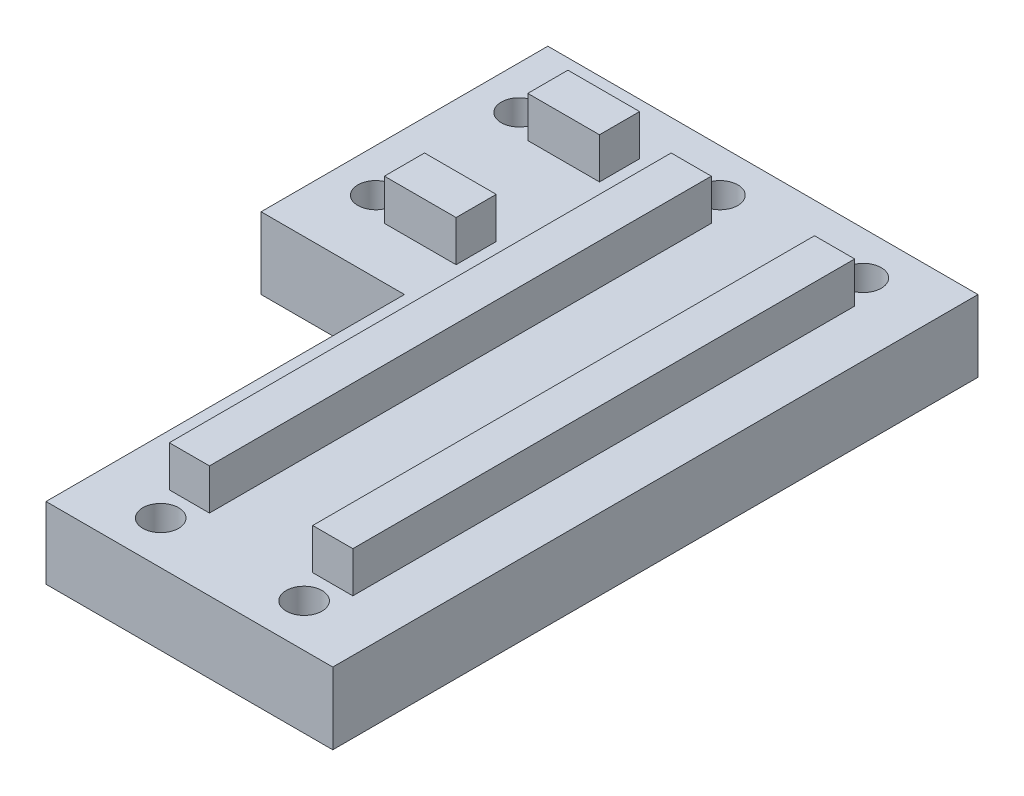
from build123d import *

# Parameters (mm, degrees)
SALIENTE_EXTRUIR1_DEPTH = 10
SALIENTE_EXTRUIR2_DEPTH = 90
SALIENTE_EXTRUIR3_DEPTH = 50
CROQUIS6_W              = 56.928573576
CROQUIS6_H              = 55.923287038
CORTAR_EXTRUIR2_DEPTH   = 30
CROQUIS5_W              = 40
CROQUIS5_H              = 10
CROQUIS5_W_2            = 10
CROQUIS5_H_2            = 40
CORTAR_EXTRUIR1_DEPTH   = 5.7
CROQUIS7_R              = 2.5
CORTAR_EXTRUIR3_DEPTH   = 11


with BuildPart() as part:
    # Croquis1 → Saliente-Extruir1 (new body)
    with BuildSketch(Plane(origin=(0, 0, 0), x_dir=(1, 0, 0), z_dir=(0, 1, 0))):
        Polygon((25, 20), (-65, 20), (-65, -20), (-15, -20), (-15, -70), (25, -70), (25, -20), align=None)
    extrude(amount=SALIENTE_EXTRUIR1_DEPTH)

    # Croquis2 → Saliente-Extruir2 (add, through all)
    with BuildSketch(Plane.XY.offset(70)):
        Polygon((12.2, 9.987376579), (12.2, 15.7), (17.8, 15.7), (17.8, 9.987376579), (15, 9.987376579), align=None)
        Polygon((-7.8, 9.987376579), (-7.8, 15.7), (-2.2, 15.7), (-2.2, 9.987376579), (-5, 9.987376579), align=None)
    extrude(amount=-SALIENTE_EXTRUIR2_DEPTH)

    # Croquis3 → Saliente-Extruir3 (add)
    with BuildSketch(Plane.ZY.offset(65)):
        Polygon((7.2, 10), (7.2, 15.7), (12.8, 15.7), (12.8, 10), (10, 10), align=None)
        Polygon((-12.8, 10), (-12.8, 15.7), (-7.2, 15.7), (-7.2, 10), (-10, 10), align=None)
    extrude(amount=-SALIENTE_EXTRUIR3_DEPTH)

    # Croquis6 → Cortar-Extruir2 (cut)
    with BuildSketch(Plane.ZY.offset(65)):
        Rectangle(CROQUIS6_W, CROQUIS6_H)
    extrude(amount=-CORTAR_EXTRUIR2_DEPTH, mode=Mode.SUBTRACT)

    # Croquis5 → Cortar-Extruir1 (cut)
    with BuildSketch(Plane(origin=(0, 15.7, 0), x_dir=(1, 0, 0), z_dir=(0, 1, 0))):
        with Locations((5, -65)):
            Rectangle(CROQUIS5_W, CROQUIS5_H)
        with Locations((5, 15)):
            Rectangle(CROQUIS5_W, CROQUIS5_H)
        with Locations((-30, 0)):
            Rectangle(CROQUIS5_W_2, CROQUIS5_H_2)
    extrude(amount=-CORTAR_EXTRUIR1_DEPTH, mode=Mode.SUBTRACT)

    # Croquis7 → Cortar-Extruir3 (cut, through all)
    with BuildSketch(Plane(origin=(0, 10, 0), x_dir=(1, 0, 0), z_dir=(0, 1, 0))):
        with Locations((-29, 10)):
            Circle(CROQUIS7_R)
        with Locations((-29, -10)):
            Circle(CROQUIS7_R)
        with Locations((15, 14)):
            Circle(CROQUIS7_R)
        with Locations((-5, 14)):
            Circle(CROQUIS7_R)
        with Locations((-5, -64)):
            Circle(CROQUIS7_R)
        with Locations((15, -64)):
            Circle(CROQUIS7_R)
    extrude(amount=-CORTAR_EXTRUIR3_DEPTH, mode=Mode.SUBTRACT)


solid = part.part
